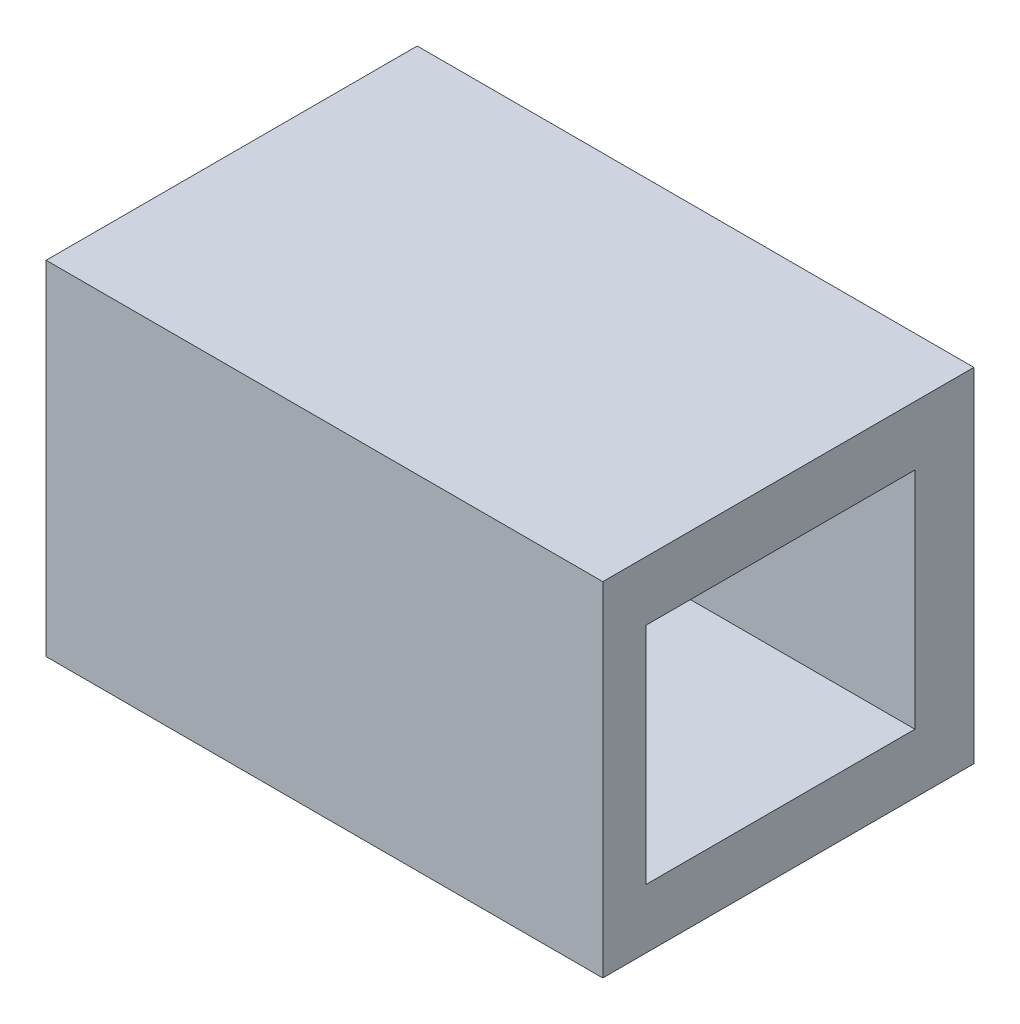
from build123d import *

# Parameters (mm, degrees)
ESQUISSE1_W             = 30
ESQUISSE1_H             = 18.5
BOSS_EXTRU_1_DEPTH      = 20
ESQUISSE2_W             = 14.5
ESQUISSE2_H             = 12.1
ENL_V_MAT_EXTRU_1_DEPTH = 39


with BuildPart() as part:
    # Esquisse1 → Boss.-Extru.1 (new body)
    with BuildSketch(Plane.XY):
        with Locations((15, 9.25)):
            Rectangle(ESQUISSE1_W, ESQUISSE1_H)
    extrude(amount=BOSS_EXTRU_1_DEPTH)

    # Esquisse2 → Enlèv. mat.-Extru.1 (cut)
    with BuildSketch(Plane(origin=(30, 0, 0), x_dir=(0, 0, -1), z_dir=(1, 0, 0))):
        with Locations((-10.427008648, 9.25)):
            Rectangle(ESQUISSE2_W, ESQUISSE2_H)
    extrude(amount=-ENL_V_MAT_EXTRU_1_DEPTH, mode=Mode.SUBTRACT)


solid = part.part
